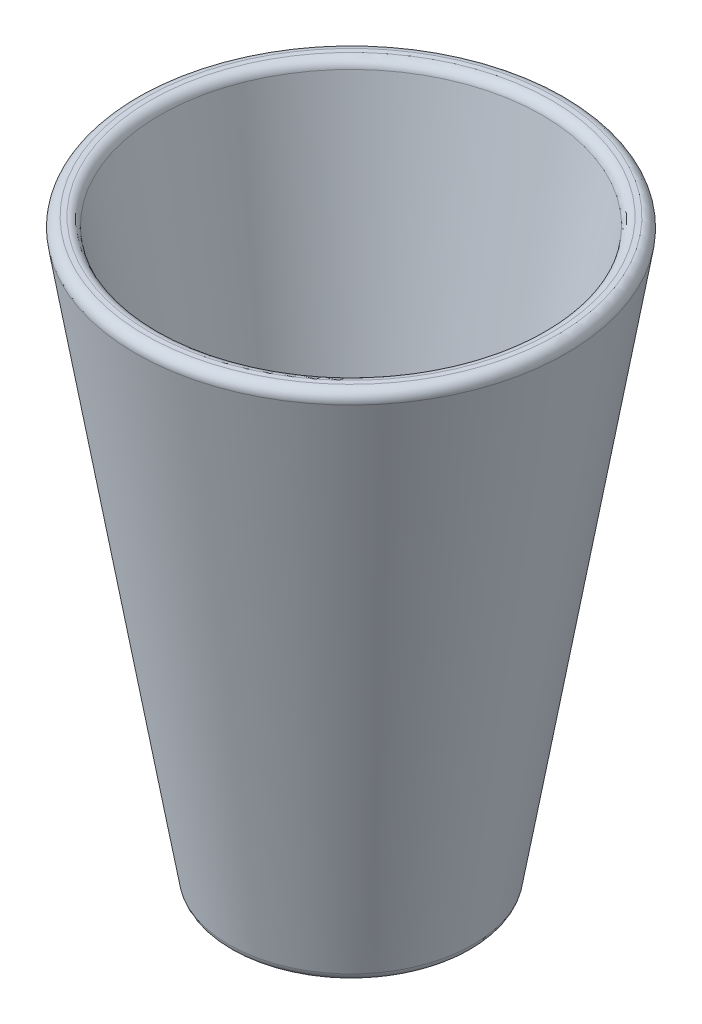
from build123d import *

# Parameters (mm, degrees)
FILLET1_R = 20


with BuildPart() as part:
    # Sketch1 → Revolve1 (revolve)
    with BuildSketch(Plane.XY):
        Polygon((0, -573.807622343), (0, -623.807622343), (250, -623.807622343), (450.694452759, 576.192377657), (400, 576.192377657), (207.667816106, -573.807622343), align=None)
    revolve(axis=Axis((0, 411.869437483, 0), (0, -1, 0)))

    # Fillet1
    fillet1_edges = [part.edges().sort_by_distance(p)[0] for p in [
        (-400, 576.192377657, 0),
        (-450.694452759, 576.192377657, 0),
        (-250, -623.807622343, 0),
    ]]
    fillet(fillet1_edges, radius=FILLET1_R)


solid = part.part
